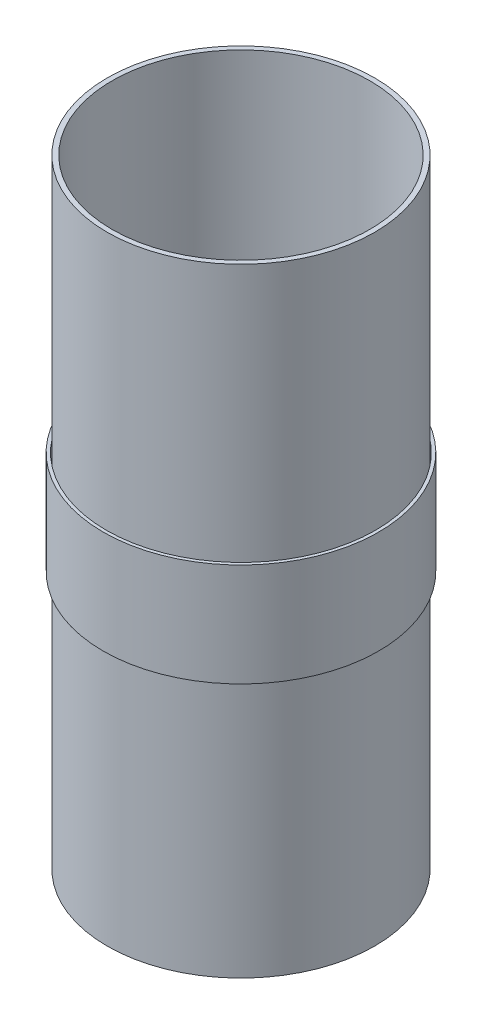
from build123d import *

# Parameters (mm, degrees)
SKETCH1_R           = 49.4538
SKETCH1_R_2         = 47.6504
BOSS_EXTRUDE1_DEPTH = 228.6
BOSS_EXTRUDE2_START = -133.35
SKETCH2_R           = 50.9524
SKETCH2_R_2         = 49.7967
BOSS_EXTRUDE2_DEPTH = 38.1


with BuildPart() as part:
    # Sketch1 → Boss-Extrude1 (new body)
    with BuildSketch(Plane(origin=(0, 0, 0), x_dir=(1, 0, 0), z_dir=(0, 1, 0))):
        Circle(SKETCH1_R)
        Circle(SKETCH1_R_2, mode=Mode.SUBTRACT)
    extrude(amount=BOSS_EXTRUDE1_DEPTH)


with BuildPart() as body_2:
    # Sketch2 → Boss-Extrude2 (new body)
    with BuildSketch(Plane(origin=(0, 228.6, 0), x_dir=(1, 0, 0), z_dir=(0, 1, 0)).offset(BOSS_EXTRUDE2_START)):
        Circle(SKETCH2_R)
        Circle(SKETCH2_R_2, mode=Mode.SUBTRACT)
    extrude(amount=BOSS_EXTRUDE2_DEPTH)


solid = Compound([part.part, body_2.part])
